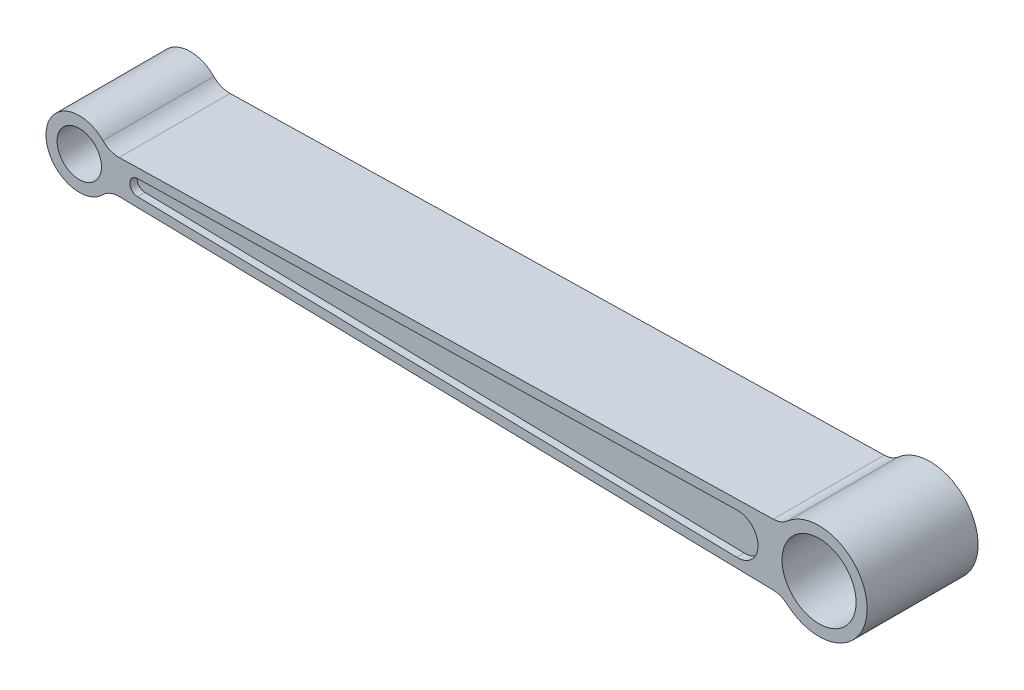
from build123d import *

# Parameters (mm, degrees)
SKETCH1_R           = 5
SKETCH1_R_2         = 3
BOSS_EXTRUDE2_DEPTH = 7.5
BOSS_EXTRUDE3_DEPTH = 6.5
FILLET1_R           = 3


with BuildPart() as part:
    # Sketch1 → Boss-Extrude2 (new, symmetric)
    with BuildSketch(Plane.XY):
        with BuildLine():
            Line((95.02071112, 4.178119463), (3.897114317, 2.25))
            ThreePointArc((3.897114317, 2.25), (-4.5, 0), (3.897114317, -2.25))
            Line((3.897114317, -2.25), (95.02071112, -4.178119463))
            ThreePointArc((95.02071112, -4.178119463), (106.5, 0), (95.02071112, 4.178119463))
        make_face()
        with BuildLine():
            ThreePointArc((7.883680433, -1.059645666), (6.824034767, 0), (7.883680433, 1.059645666))
            Line((7.883680433, 1.059645666), (88.855952705, 2.772969323))
            ThreePointArc((88.855952705, 2.772969323), (91.748807392, 0), (88.855952705, -2.772969323))
            Line((88.855952705, -2.772969323), (7.883680433, -1.059645666))
        make_face(mode=Mode.SUBTRACT)
        with Locations((100, 0)):
            Circle(SKETCH1_R, mode=Mode.SUBTRACT)
        Circle(SKETCH1_R_2, mode=Mode.SUBTRACT)
    extrude(amount=BOSS_EXTRUDE2_DEPTH, both=True)

    # Sketch1_7 → Boss-Extrude3 (add, symmetric)
    with BuildSketch(Plane.XY):
        with BuildLine():
            Line((88.855952705, 2.772969323), (7.883680433, 1.059645666))
            ThreePointArc((7.883680433, 1.059645666), (6.824034767, 0), (7.883680433, -1.059645666))
            Line((7.883680433, -1.059645666), (88.855952705, -2.772969323))
            Line((88.855952705, -2.772969323), (88.973353931, -2.775453461))
            ThreePointArc((88.973353931, -2.775453461), (91.748807392, 0), (88.973353931, 2.775453461))
            Line((88.973353931, 2.775453461), (88.855952705, 2.772969323))
        make_face()
    extrude(amount=BOSS_EXTRUDE3_DEPTH, both=True)

    # Fillet1
    fillet1_edges = [part.edges().sort_by_distance(p)[0] for p in [
        (95.02071112, -4.178119463, 0),
        (3.897114317, -2.25, 0),
        (3.897114317, 2.25, 0),
        (95.02071112, 4.178119463, 0),
    ]]
    fillet(fillet1_edges, radius=FILLET1_R)


solid = part.part
